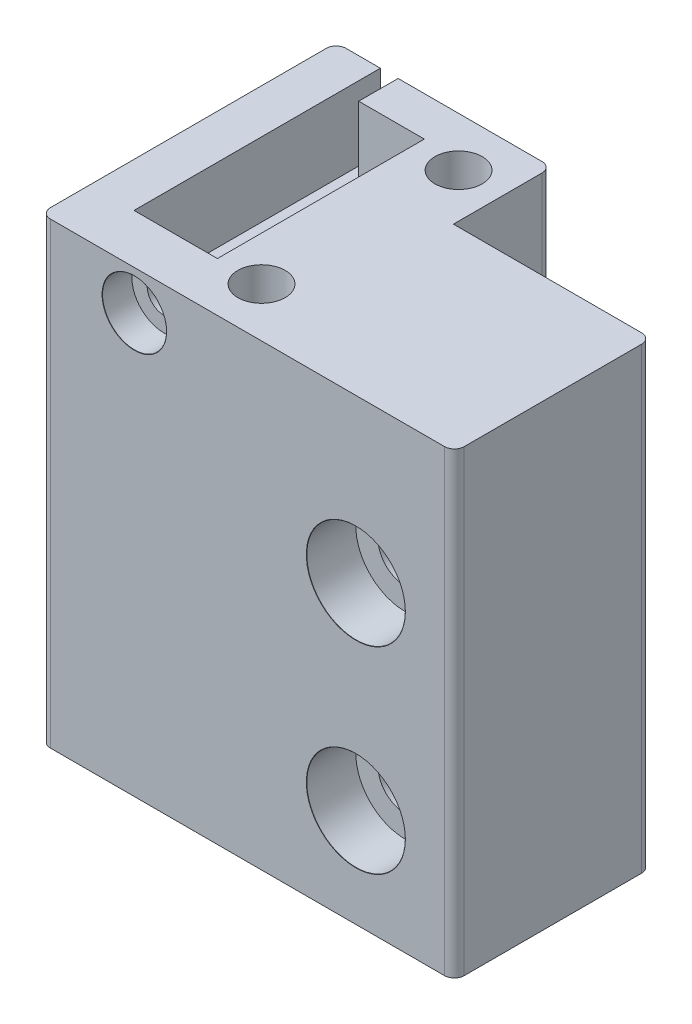
from build123d import *

# Parameters (mm, degrees)
SKETCH1_W                     = 42
SKETCH1_H                     = 20
BOSS_EXTRUDE1_DEPTH           = 40
CBORE_FOR_M5_SHCS1_AT_2_COUNT = 2
CBORE_FOR_M5_SHCS1_AT_2_PITCH = 20
SKETCH5_W                     = 42
SKETCH5_H                     = 20
BOSS_EXTRUDE2_DEPTH           = 6.5
SKETCH12_W                    = 21.9
SKETCH12_H                    = 10
BOSS_EXTRUDE3_DEPTH           = 46.5
CUT_EXTRUDE1_DEPTH            = 7.5
FILLET1_R                     = 1
SKETCH14_R                    = 2.4
CUT_EXTRUDE2_DEPTH            = 3.8
SKETCH15_R                    = 1.7
CUT_EXTRUDE3_DEPTH            = 3


with BuildPart() as part:
    # Sketch1 → Boss-Extrude1 (new body)
    with BuildSketch(Plane(origin=(0, 0, 0), x_dir=(1, 0, 0), z_dir=(0, 1, 0))):
        Rectangle(SKETCH1_W, SKETCH1_H)
    extrude(amount=BOSS_EXTRUDE1_DEPTH)

    # Sketch4 → CBORE for M5 SHCS1 (revolve, cut)
    with BuildSketch(Plane(origin=(11, 30, 10), x_dir=(0, -1, 0), z_dir=(1, 0, 0))):
        Polygon((0, 0), (0, 20), (2.75, 20), (2.75, 5), (5, 5), (5, 0.020977491), (5.025, 0), align=None)
    cbore_for_m5_shcs1 = revolve(axis=Axis((11, 30, 16.35), (0, 0, -1)), mode=Mode.SUBTRACT)

    # CBORE for M5 SHCS1 at 2: CBORE for M5 SHCS1 ×2
    with Locations(*[(0, -i * CBORE_FOR_M5_SHCS1_AT_2_PITCH, 0) for i in range(1, CBORE_FOR_M5_SHCS1_AT_2_COUNT)]):
        add(cbore_for_m5_shcs1, mode=Mode.SUBTRACT)

    # Sketch5 → Boss-Extrude2 (add)
    with BuildSketch(Plane(origin=(0, 40, 0), x_dir=(1, 0, 0), z_dir=(0, 1, 0))):
        Rectangle(SKETCH5_W, SKETCH5_H)
    extrude(amount=BOSS_EXTRUDE2_DEPTH)

    # Sketch12 → Boss-Extrude3 (add)
    with BuildSketch(Plane(origin=(0, 46.5, 0), x_dir=(1, 0, 0), z_dir=(0, 1, 0))):
        with Locations((-10.05, 15)):
            Rectangle(SKETCH12_W, SKETCH12_H)
    extrude(amount=-BOSS_EXTRUDE3_DEPTH)

    # Sketch6 → Cut-Extrude1 (cut)
    with BuildSketch(Plane(origin=(0, 46.5, 0), x_dir=(1, 0, 0), z_dir=(0, 1, 0))):
        Polygon((-16.51, 20), (-16.51, -5), (-8.05, -5), (-8.05, 16), (-14.71, 16), (-14.71, 20), align=None)
    extrude(amount=-CUT_EXTRUDE1_DEPTH, mode=Mode.SUBTRACT)

    # Fillet1
    fillet1_edges = [part.edges().sort_by_distance(p)[0] for p in [
        (0.9, 23.25, -20),
        (-21, 23.25, -20),
        (21, 23.25, -10),
        (21, 23.25, 10),
        (-21, 23.25, 10),
    ]]
    fillet(fillet1_edges, radius=FILLET1_R)

    # Sketch11 → CBORE for M3 SHCS1 (revolve, cut)
    with BuildSketch(Plane(origin=(-11.48, 42.5, 10), x_dir=(0, -1, 0), z_dir=(1, 0, 0))):
        Polygon((0, 0), (0, 6.021463052), (1.7, 5), (1.7, 3), (3.25, 3), (3.25, 0.020977491), (3.275, 0), align=None)
    revolve(axis=Axis((-11.48, 42.5, 16.35), (0, 0, -1)), mode=Mode.SUBTRACT)

    # Sketch14 → Cut-Extrude2 (cut)
    with BuildSketch(Plane(origin=(0, 46.5, 0), x_dir=(1, 0, 0), z_dir=(0, 1, 0))):
        with Locations((-3.575, 15)):
            Circle(SKETCH14_R)
        with Locations((-3.575, -5)):
            Circle(SKETCH14_R)
    extrude(amount=-CUT_EXTRUDE2_DEPTH, mode=Mode.SUBTRACT)

    # Sketch15 → Cut-Extrude3 (cut)
    with BuildSketch(Plane(origin=(0, 42.7, 0), x_dir=(1, 0, 0), z_dir=(0, 1, 0))):
        with Locations((-3.575, 15)):
            Circle(SKETCH15_R)
        with Locations((-3.575, -5)):
            Circle(SKETCH15_R)
    extrude(amount=-CUT_EXTRUDE3_DEPTH, mode=Mode.SUBTRACT)


solid = part.part
